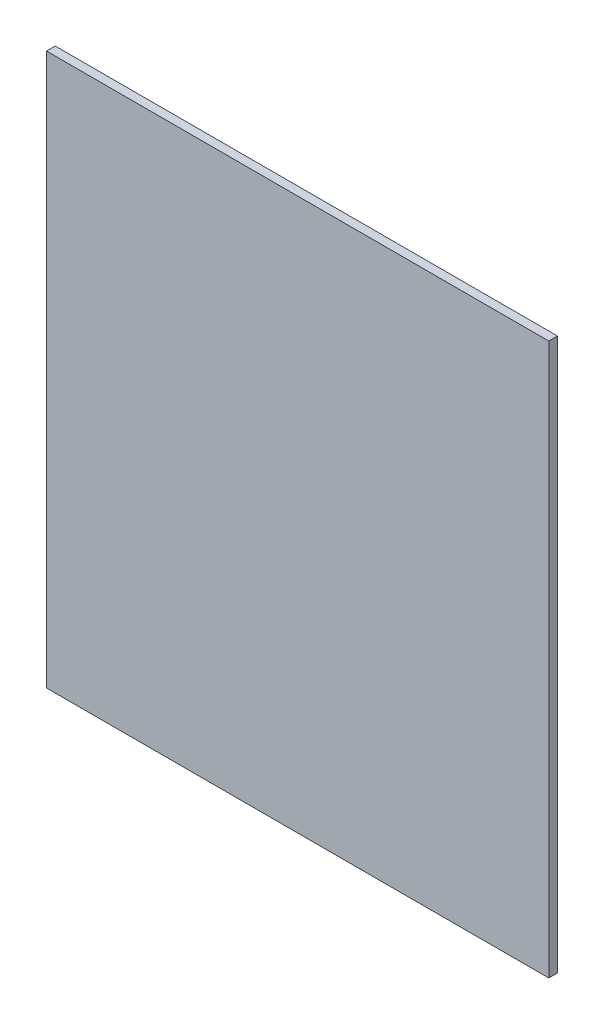
from build123d import *

# Parameters (mm, degrees)
ESQUISSE1_W        = 173
ESQUISSE1_H        = 190
BOSS_EXTRU_1_DEPTH = 3


with BuildPart() as part:
    # Esquisse1 → Boss.-Extru.1 (new body)
    with BuildSketch(Plane.XY):
        with Locations((349.339330179, -59.448678033)):
            Rectangle(ESQUISSE1_W, ESQUISSE1_H)
    extrude(amount=BOSS_EXTRU_1_DEPTH)


solid = part.part
